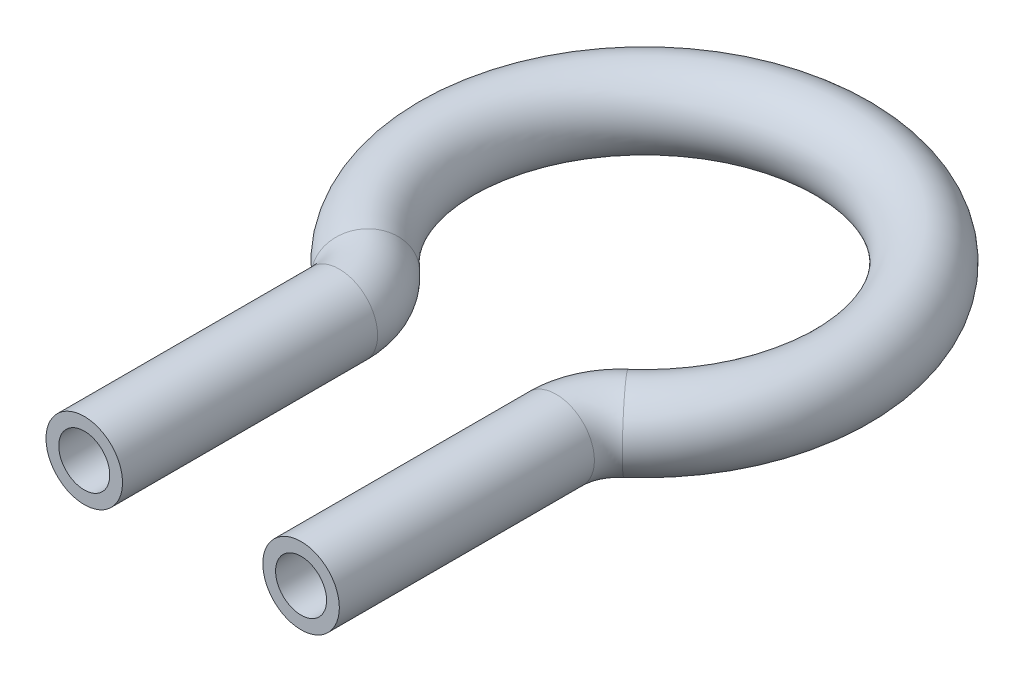
from build123d import *

# Parameters (mm, degrees)
SKETCH2_R   = 3
SKETCH2_R_2 = 2


with BuildPart() as part:
    # Sweep1: sweep along a path in Sketch1
    with BuildLine(Plane(origin=(0, 0, 0), x_dir=(1, 0, 0), z_dir=(0, 1, 0))) as sweep1_path:
        Line((8.5, -35.427248621), (8.5, -15.427248621))
        ThreePointArc((8.5, -15.427248621), (8.946791536, -13.361263944), (10.207317073, -11.664505055))
        ThreePointArc((10.207317073, -11.664505055), (0, 15.5), (-10.207317073, -11.664505055))
        ThreePointArc((-10.207317073, -11.664505055), (-8.946791536, -13.361263944), (-8.5, -15.427248621))
        Line((-8.5, -15.427248621), (-8.5, -35.427248621))
    # Sketch2 → Sweep1 (sweep)
    with BuildSketch(Plane(origin=(-8.5, 0, 35.427248621), x_dir=(-1, 0, 0), z_dir=(0, 0, -1))):
        Circle(SKETCH2_R)
        Circle(SKETCH2_R_2, mode=Mode.SUBTRACT)
    sweep(path=sweep1_path.line)


solid = part.part
